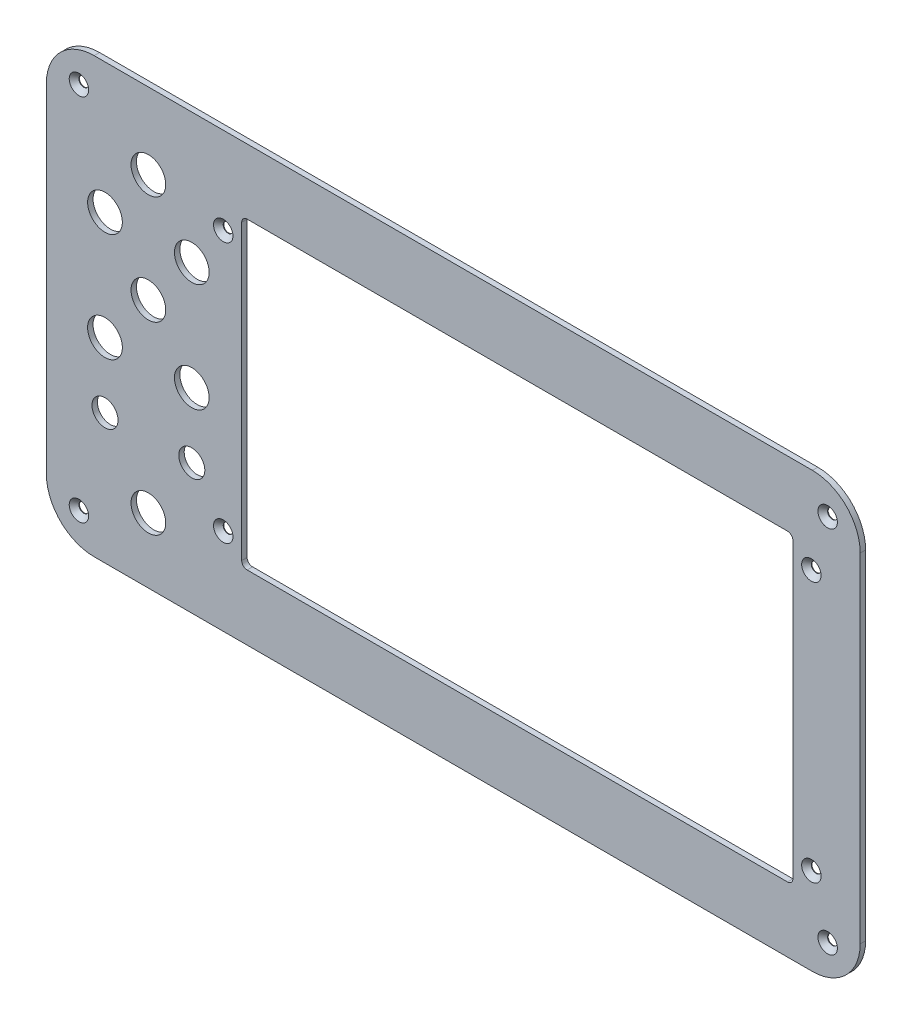
from build123d import *

# Parameters (mm, degrees)
EXTRUDE1_DEPTH                                 = 1.25
CUT_EXTRUDE4_DEPTH                             = 3.5
ESBO_O6_R                                      = 8
ESBO_O6_R_2                                    = 6
CORTE_EXTRUS_O1_DEPTH                          = 10
ESBO_O7_R                                      = 1
CORTE_EXTRUS_O2_DEPTH                          = 3.5
ESCAREADO_PARA_PARAFUSO_ALLEN_SEXTAV_2_A_COUNT = 2
ESCAREADO_PARA_PARAFUSO_ALLEN_SEXTAV_2_A_PITCH = 120
ESCAREADO_PARA_PARAFUSO_ALLEN_SEXTAV_3_COUNT   = 2
ESCAREADO_PARA_PARAFUSO_ALLEN_SEXTAV_3_PITCH   = 296.379823875
ESCAREADO_PARA_PARAFUSO_ALLEN_SEXTAV_4_COUNT   = 2
ESCAREADO_PARA_PARAFUSO_ALLEN_SEXTAV_4_PITCH   = 271


with BuildPart() as part:
    # Sketch1 → Extrude1 (new body, symmetric)
    with BuildSketch(Plane.XY):
        with BuildLine():
            Line((-165.5, 100), (165.5, 100))
            ThreePointArc((165.5, 100), (181.056349186, 93.556349186), (187.5, 78))
            Line((187.5, 78), (187.5, -78))
            ThreePointArc((187.5, -78), (181.056349186, -93.556349186), (165.5, -100))
            Line((165.5, -100), (-165.5, -100))
            ThreePointArc((-165.5, -100), (-181.056349186, -93.556349186), (-187.5, -78))
            Line((-187.5, -78), (-187.5, 78))
            ThreePointArc((-187.5, 78), (-181.056349186, 93.556349186), (-165.5, 100))
        make_face()
    extrude(amount=EXTRUDE1_DEPTH, both=True)

    # Sketch5 → Cut-Extrude4 (cut, through all)
    with BuildSketch(Plane.XY.offset(1.25)):
        with BuildLine():
            Line((-95, 70), (154, 70))
            ThreePointArc((154, 70), (155.767766953, 69.267766953), (156.5, 67.5))
            Line((156.5, 67.5), (156.5, -67.5))
            ThreePointArc((156.5, -67.5), (155.767766953, -69.267766953), (154, -70))
            Line((154, -70), (-95, -70))
            ThreePointArc((-95, -70), (-96.767766953, -69.267766953), (-97.5, -67.5))
            Line((-97.5, -67.5), (-97.5, 67.5))
            ThreePointArc((-97.5, 67.5), (-96.767766953, 69.267766953), (-95, 70))
        make_face()
    extrude(amount=-CUT_EXTRUDE4_DEPTH, mode=Mode.SUBTRACT)

    # Esboço1 → Escareado para parafuso Allen sextavado (revolve, cut)
    with BuildSketch(Plane(origin=(172.5, 85, 1.25), x_dir=(0, -1, 0), z_dir=(1, 0, 0))):
        Polygon((0, 0), (0, 2.5), (2.25, 2.5), (2.25, 2.23), (4.48, 0), align=None)
    escareado_para_parafuso_allen_sextavado = revolve(axis=Axis((172.5, 85, 7.6), (0, 0, -1)), mode=Mode.SUBTRACT)

    # Espelhar2: Escareado para parafuso Allen sextavado across plane
    add(escareado_para_parafuso_allen_sextavado.mirror(Plane(origin=(0, 0, 0), x_dir=(0, 0, 1), z_dir=(1, 0, 0))), mode=Mode.SUBTRACT)

    # Espelhar3: Escareado para parafuso Allen sextavado across plane
    add(escareado_para_parafuso_allen_sextavado.mirror(Plane.ZX), mode=Mode.SUBTRACT)

    # Espelhar3 copy 1 sketch → Espelhar3 copy 1 (revolve, cut)
    with BuildSketch(Plane(origin=(-172.5, -85, 1.25), x_dir=(0, 1, 0), z_dir=(-1, 0, 0))):
        Polygon((0, 0), (0, 2.5), (2.25, 2.5), (2.25, 2.23), (4.48, 0), align=None)
    revolve(axis=Axis((-172.5, -85, 7.6), (0, 0, -1)), mode=Mode.SUBTRACT)

    # Esboço6 → Corte-extrusão1 (cut)
    with BuildSketch(Plane.XY.offset(1.25)):
        with Locations((-140.5, 65)):
            Circle(ESBO_O6_R)
        with Locations((-120.5, 40)):
            Circle(ESBO_O6_R)
        with Locations((-160.5, 40)):
            Circle(ESBO_O6_R)
        with Locations((-140.5, 15)):
            Circle(ESBO_O6_R)
        with Locations((-120.5, -10)):
            Circle(ESBO_O6_R)
        with Locations((-160.5, -10)):
            Circle(ESBO_O6_R)
        with Locations((-140.5, -70)):
            Circle(ESBO_O6_R)
        with Locations((-120.5, -40)):
            Circle(ESBO_O6_R_2)
        with Locations((-160.5, -40)):
            Circle(ESBO_O6_R_2)
    extrude(amount=-CORTE_EXTRUS_O1_DEPTH, mode=Mode.SUBTRACT)

    # Esboço7 → Corte-extrusão2 (cut, through all)
    with BuildSketch(Plane.XY.offset(1.25)):
        with Locations((-106, -60)):
            Circle(ESBO_O7_R)
        with Locations((-106, 60)):
            Circle(ESBO_O7_R)
        with Locations((165, 60)):
            Circle(ESBO_O7_R)
        with Locations((165, -60)):
            Circle(ESBO_O7_R)
    extrude(amount=-CORTE_EXTRUS_O2_DEPTH, mode=Mode.SUBTRACT)

    # Esboço11 → Escareado para parafuso Allen sextav 2 (revolve, cut)
    with BuildSketch(Plane(origin=(-106, 60, 1.25), x_dir=(0, -1, 0), z_dir=(1, 0, 0))):
        Polygon((0, 0), (0, 2.5), (2.25, 2.5), (2.25, 2.23), (4.48, 0), align=None)
    escareado_para_parafuso_allen_sextav_2 = revolve(axis=Axis((-106, 60, 7.6), (0, 0, -1)), mode=Mode.SUBTRACT)

    # Escareado para parafuso Allen sextav 2 a: Escareado para parafuso Allen sextav 2 ×2
    with Locations(*[(0, -i * ESCAREADO_PARA_PARAFUSO_ALLEN_SEXTAV_2_A_PITCH, 0) for i in range(1, ESCAREADO_PARA_PARAFUSO_ALLEN_SEXTAV_2_A_COUNT)]):
        add(escareado_para_parafuso_allen_sextav_2, mode=Mode.SUBTRACT)

    # Escareado para parafuso Allen sextav 3: Escareado para parafuso Allen sextav 2 ×2
    with Locations(*[Vector(0.914367235, -0.40488586, 0) * (i * ESCAREADO_PARA_PARAFUSO_ALLEN_SEXTAV_3_PITCH) for i in range(1, ESCAREADO_PARA_PARAFUSO_ALLEN_SEXTAV_3_COUNT)]):
        add(escareado_para_parafuso_allen_sextav_2, mode=Mode.SUBTRACT)

    # Escareado para parafuso Allen sextav 4: Escareado para parafuso Allen sextav 2 ×2
    with Locations(*[(i * ESCAREADO_PARA_PARAFUSO_ALLEN_SEXTAV_4_PITCH, 0, 0) for i in range(1, ESCAREADO_PARA_PARAFUSO_ALLEN_SEXTAV_4_COUNT)]):
        add(escareado_para_parafuso_allen_sextav_2, mode=Mode.SUBTRACT)


solid = part.part
